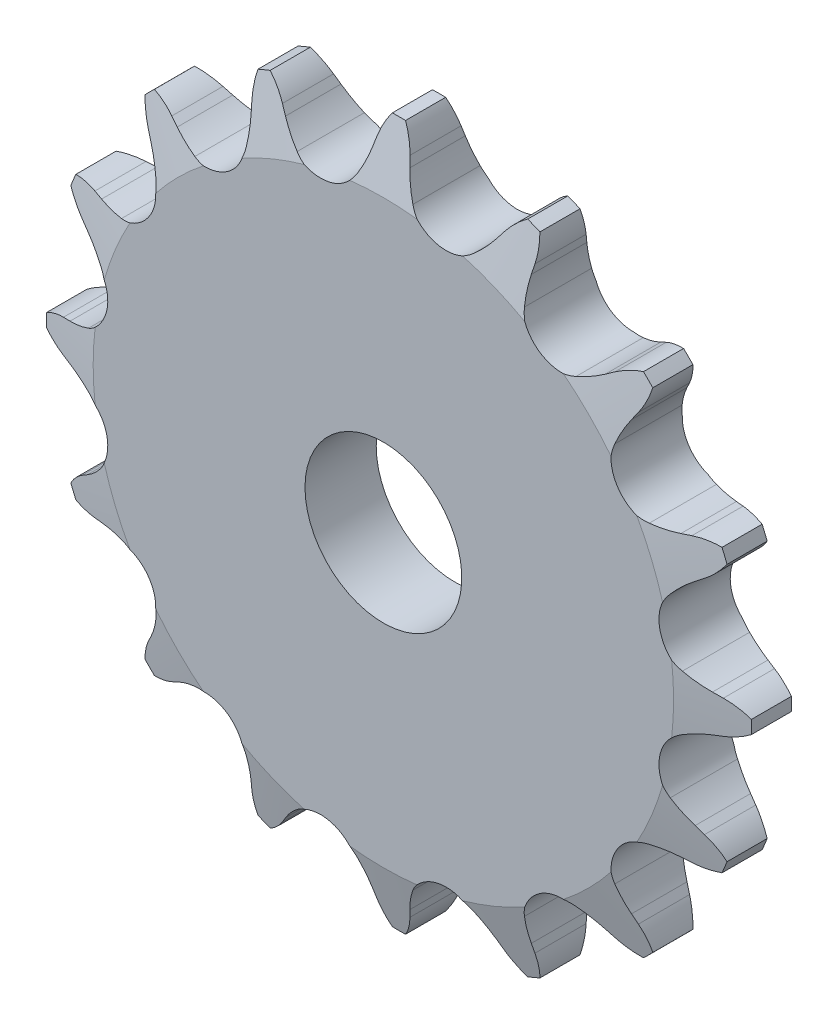
from build123d import *

# Parameters (mm, degrees)
CUT_EXTRUDE1_DEPTH      = 51.663499382
CIRPATTERN1_COUNT       = 16
CUT_EXTRUDE2_DEPTH      = 51.66349953
CUT_EXTRUDE2_DEPTH_BACK = 51.66349953
SKETCH3_OUTSIDE_W       = 93.734
SKETCH3_OUTSIDE_H       = 93.734
SKETCH3_OUTSIDE_R       = 35.687
SKETCH3_OUTSIDE_R_2     = 7.9375


with BuildPart() as part:
    # Sketch1 → Revolve1 (revolve)
    with BuildSketch(Plane(origin=(0, 0, 0), x_dir=(0, 0, -1), z_dir=(1, 0, 0)), mode=Mode.PRIVATE) as revolve1_sk:
        Polygon((3.6068, 0), (-3.6068, 0), (-3.6068, 29.383605775), (-2.0193, 35.733605775), (2.0193, 35.733605775), (3.6068, 29.383605775), align=None)
    revolve(revolve1_sk.sketch.rotate(Axis((0, 0, -3.6068), (0, 0, 1)), 90), axis=Axis((0, 0, -3.6068), (0, 0, 1)))

    # Sketch0 → Cut-Extrude1 (cut, symmetric)
    with BuildSketch(Plane.XY):
        with BuildLine():
            Line((11.236700363, -31.503576461), (10.709189916, -30.764034089))
            ThreePointArc((10.709189916, -30.764034089), (9.882522215, -29.747726076), (8.934206741, -28.843868108))
            ThreePointArc((8.934206741, -28.843868108), (5.565676037, -27.980542943), (2.783939703, -30.067232284))
            ThreePointArc((2.783939703, -30.067232284), (2.253701915, -31.265192782), (1.878884785, -32.520490988))
            Line((1.878884785, -32.520490988), (1.674539293, -33.405608556))
            ThreePointArc((1.674539293, -33.405608556), (-1.034704292, -37.367777481), (-5.713254396, -38.440135775))
            ThreePointArc((-5.713254396, -38.440135775), (7.581676073, -38.115659539), (19.988761899, -33.327686867))
            ThreePointArc((19.988761899, -33.327686867), (15.255971463, -34.1273606), (11.236700363, -31.503576461))
        make_face()
    cut_extrude1 = extrude(amount=CUT_EXTRUDE1_DEPTH, both=True, mode=Mode.SUBTRACT)

    # CirPattern1: Cut-Extrude1 ×16 about axis
    cirpattern1_axis = Axis((0, 0, 0), (0, 0, 1))
    for i in range(1, CIRPATTERN1_COUNT):
        add(cut_extrude1.rotate(cirpattern1_axis, i * 360 / CIRPATTERN1_COUNT), mode=Mode.SUBTRACT)

    # Sketch3 outside → Cut-Extrude2 (cut, two sides: drawn at the far end of the back side and taken through both)
    # profile 1 of 2: a face of its own
    with BuildSketch(Plane.XY.offset(-CUT_EXTRUDE2_DEPTH_BACK)):
        Rectangle(SKETCH3_OUTSIDE_W, SKETCH3_OUTSIDE_H)
        Circle(SKETCH3_OUTSIDE_R, mode=Mode.SUBTRACT)
    # profile 2 of 2: a face of its own
    with BuildSketch(Plane.XY.offset(-CUT_EXTRUDE2_DEPTH_BACK)):
        with Locations(Location((0, 0, 0), (0, 0, 180))):
            Circle(SKETCH3_OUTSIDE_R_2)
    extrude(amount=CUT_EXTRUDE2_DEPTH + CUT_EXTRUDE2_DEPTH_BACK, mode=Mode.SUBTRACT)


solid = part.part
